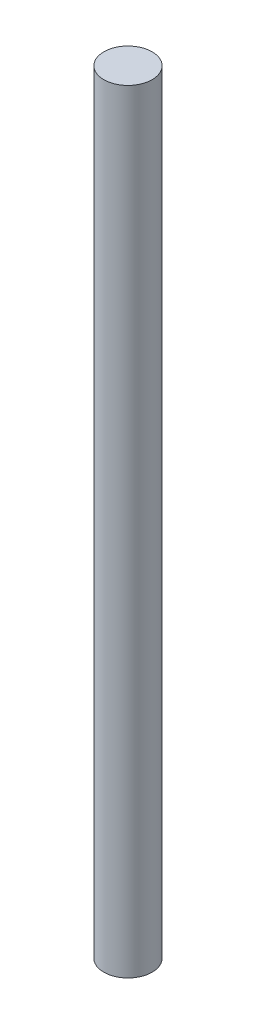
from build123d import *

# Parameters (mm, degrees)
SKETCH1_R           = 9.525
BOSS_EXTRUDE1_DEPTH = 304.8


with BuildPart() as part:
    # Sketch1 → Boss-Extrude1 (new body)
    with BuildSketch(Plane(origin=(0, 0, 0), x_dir=(1, 0, 0), z_dir=(0, 1, 0))):
        Circle(SKETCH1_R)
    extrude(amount=BOSS_EXTRUDE1_DEPTH)


solid = part.part
